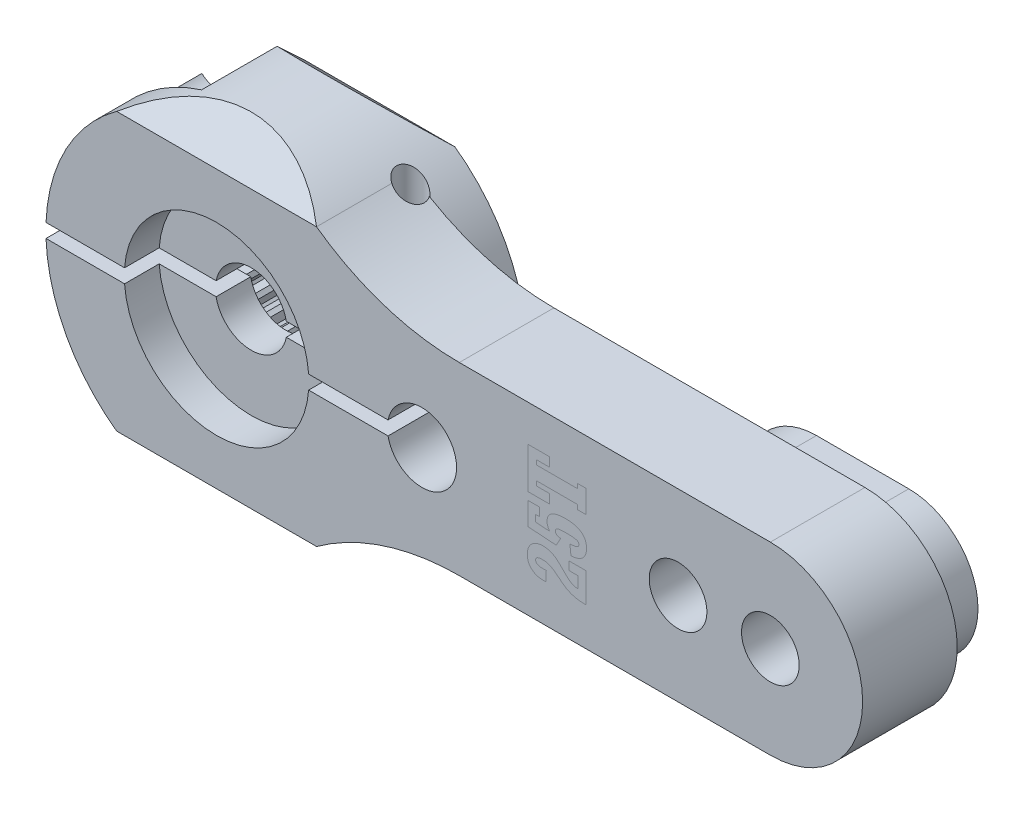
from build123d import *

# Parameters (mm, degrees)
SKETCH1_R                    = 7.4
SKETCH1_R_2                  = 1.55
BOSS_EXTRUDE1_DEPTH          = 6
SKETCH2_R                    = 1.55
BOSS_EXTRUDE2_DEPTH          = 4.1
BOSS_EXTRUDE3_DEPTH          = 7
CUT_EXTRUDE1_START           = -3
SKETCH4_R                    = 2.65
CUT_EXTRUDE1_DEPTH           = 5
CHAMFER1_SIZE                = 0.45
CUT_EXTRUDE2_START           = -3
CUT_EXTRUDE2_DEPTH           = 5
CIRPATTERN1_COUNT            = 25
CUT_EXTRUDE3_START           = -1.6
CUT_EXTRUDE3_DEPTH           = 6.4
SKETCH7_R                    = 0.6
CUT_EXTRUDE4_DEPTH           = 8.4
CUT_EXTRUDE4_DEPTH_BACK      = 8.4
SKETCH8_R                    = 1.5
SKETCH8_R_2                  = 1.25
CUT_EXTRUDE5_DEPTH           = 8
SKETCH9_W                    = 20.948807496
SKETCH9_H                    = 0.6
CUT_EXTRUDE6_DEPTH           = 1.0000001
CUT_EXTRUDE6_DEPTH_BACK      = 8
CUT_EXTRUDE_THIN1_DEPTH      = 29
CUT_EXTRUDE_THIN1_DEPTH_BACK = 8.393916518
SKETCH11_R                   = 4
CUT_EXTRUDE7_DEPTH           = 1.5


with BuildPart() as part:
    # Sketch1 → Boss-Extrude1 (new body)
    with BuildSketch(Plane.XY):
        Circle(SKETCH1_R)
        Circle(SKETCH1_R_2, mode=Mode.SUBTRACT)
    extrude(amount=-BOSS_EXTRUDE1_DEPTH)

    # Sketch2 → Boss-Extrude2 (add)
    with BuildSketch(Plane.XY):
        with BuildLine():
            Line((24, 4), (10.518826659, 4))
            ThreePointArc((10.518826659, 4), (7.267453323, 4.512419004), (4.331281566, 6))
            ThreePointArc((4.331281566, 6), (-7.4, 0), (4.331281566, -6))
            ThreePointArc((4.331281566, -6), (7.267453323, -4.512419004), (10.518826659, -4))
            Line((10.518826659, -4), (24, -4))
            ThreePointArc((24, -4), (28, 0), (24, 4))
        make_face()
        Circle(SKETCH2_R, mode=Mode.SUBTRACT)
    extrude(amount=-BOSS_EXTRUDE2_DEPTH)

    # Sketch3 → Boss-Extrude3 (add)
    with BuildSketch(Plane.XY):
        with BuildLine():
            Line((20, 3), (24, 3))
            ThreePointArc((24, 3), (27, 0), (24, -3))
            Line((24, -3), (20, -3))
            ThreePointArc((20, -3), (17, 0), (20, 3))
        make_face()
    extrude(amount=-BOSS_EXTRUDE3_DEPTH)

    # Sketch4 → Cut-Extrude1 (cut, through all)
    with BuildSketch(Plane.XY.offset(CUT_EXTRUDE1_START)):
        Circle(SKETCH4_R)
    extrude(amount=-CUT_EXTRUDE1_DEPTH, mode=Mode.SUBTRACT)

    # Chamfer1
    chamfer1_edges = [part.edges().sort_by_distance(p)[0] for p in [
        (-2.65, 0, -6),
    ]]
    chamfer(chamfer1_edges, length=CHAMFER1_SIZE)

    # Sketch5 → Cut-Extrude2 (cut, through all)
    with BuildSketch(Plane.XY.offset(CUT_EXTRUDE2_START)):
        with BuildLine():
            Line((0.100653791, 2.648087766), (0.320281942, 3.033136904))
            ThreePointArc((0.320281942, 3.033136904), (0.382266362, 3.025949839), (0.444090779, 3.01749621))
            Line((0.444090779, 3.01749621), (0.561061081, 2.589924799))
            ThreePointArc((0.561061081, 2.589924799), (0.332133069, 2.629103958), (0.100653791, 2.648087766))
        make_face()
    cut_extrude2 = extrude(amount=-CUT_EXTRUDE2_DEPTH, mode=Mode.SUBTRACT)

    # CirPattern1: Cut-Extrude2 ×25 about axis
    cirpattern1_axis = Axis((0, 0, 0), (0, 0, 1))
    for i in range(1, CIRPATTERN1_COUNT):
        add(cut_extrude2.rotate(cirpattern1_axis, i * 360 / CIRPATTERN1_COUNT), mode=Mode.SUBTRACT)

    # Sketch6 → Cut-Extrude3 (cut, through all)
    with BuildSketch(Plane.XY.offset(CUT_EXTRUDE3_START)):
        with BuildLine():
            Line((3.25, -3), (5.95, -3))
            ThreePointArc((5.95, -3), (6.657106781, -3.292893219), (6.95, -4))
            Line((6.95, -4), (6.95, -12.29125861))
            Line((6.95, -12.29125861), (2.25, -12.29125861))
            Line((2.25, -12.29125861), (2.25, -4))
            ThreePointArc((2.25, -4), (2.542893219, -3.292893219), (3.25, -3))
        make_face()
        with BuildLine():
            Line((-6.95, 12.29125861), (-2.25, 12.29125861))
            Line((-2.25, 12.29125861), (-2.25, 4))
            ThreePointArc((-2.25, 4), (-2.542893219, 3.292893219), (-3.25, 3))
            Line((-3.25, 3), (-5.95, 3))
            ThreePointArc((-5.95, 3), (-6.657106781, 3.292893219), (-6.95, 4))
            Line((-6.95, 4), (-6.95, 12.29125861))
        make_face()
    extrude(amount=-CUT_EXTRUDE3_DEPTH, mode=Mode.SUBTRACT)

    # Sketch7 → Cut-Extrude4 (cut, two sides)
    with BuildSketch(Plane(origin=(0, 0, 0), x_dir=(1, 0, 0), z_dir=(0, 1, 0))) as cut_extrude4_sk:
        with Locations((-4.6, 3.8)):
            Circle(SKETCH7_R)
        with Locations((4.6, 3.8)):
            Circle(SKETCH7_R)
    extrude(amount=CUT_EXTRUDE4_DEPTH, mode=Mode.SUBTRACT)
    extrude(cut_extrude4_sk.sketch, amount=-CUT_EXTRUDE4_DEPTH_BACK, mode=Mode.SUBTRACT)

    # Sketch8 → Cut-Extrude5 (cut, through all)
    with BuildSketch(Plane.XY):
        with Locations((8.9, 0)):
            Circle(SKETCH8_R)
        with Locations((20, 0)):
            Circle(SKETCH8_R_2)
        with Locations((24, 0)):
            Circle(SKETCH8_R_2)
    extrude(amount=-CUT_EXTRUDE5_DEPTH, mode=Mode.SUBTRACT)

    # Sketch9 → Cut-Extrude6 (cut, two sides)
    with BuildSketch(Plane.XY) as cut_extrude6_sk:
        with Locations((-1.574403748, 0)):
            Rectangle(SKETCH9_W, SKETCH9_H)
    extrude(amount=CUT_EXTRUDE6_DEPTH, mode=Mode.SUBTRACT)
    extrude(cut_extrude6_sk.sketch, amount=-CUT_EXTRUDE6_DEPTH_BACK, mode=Mode.SUBTRACT)

    # Sketch10 → Cut-Extrude-Thin1 (cut, two sides)
    with BuildSketch(Plane(origin=(0, 0, 0), x_dir=(0, 0, -1), z_dir=(1, 0, 0))) as cut_extrude_thin1_sk:
        Polygon((-10, 10.345523019), (-10, -10.345523019), (-2.441631806, -17.4), (8.441631806, -17.4), (16, -10.345523019), (16, 10.345523019), (8.441631806, 17.4), (-2.441631806, 17.4), align=None)
        Polygon((0, 6), (0, -6), (1.5, -7.4), (4.5, -7.4), (6, -6), (6, 6), (4.5, 7.4), (1.5, 7.4), align=None, mode=Mode.SUBTRACT)
    extrude(amount=CUT_EXTRUDE_THIN1_DEPTH, mode=Mode.SUBTRACT)
    extrude(cut_extrude_thin1_sk.sketch, amount=-CUT_EXTRUDE_THIN1_DEPTH_BACK, mode=Mode.SUBTRACT)

    # Sketch11 → Cut-Extrude7 (cut)
    with BuildSketch(Plane.XY):
        Circle(SKETCH11_R)
    extrude(amount=-CUT_EXTRUDE7_DEPTH, mode=Mode.SUBTRACT)


solid = part.part
